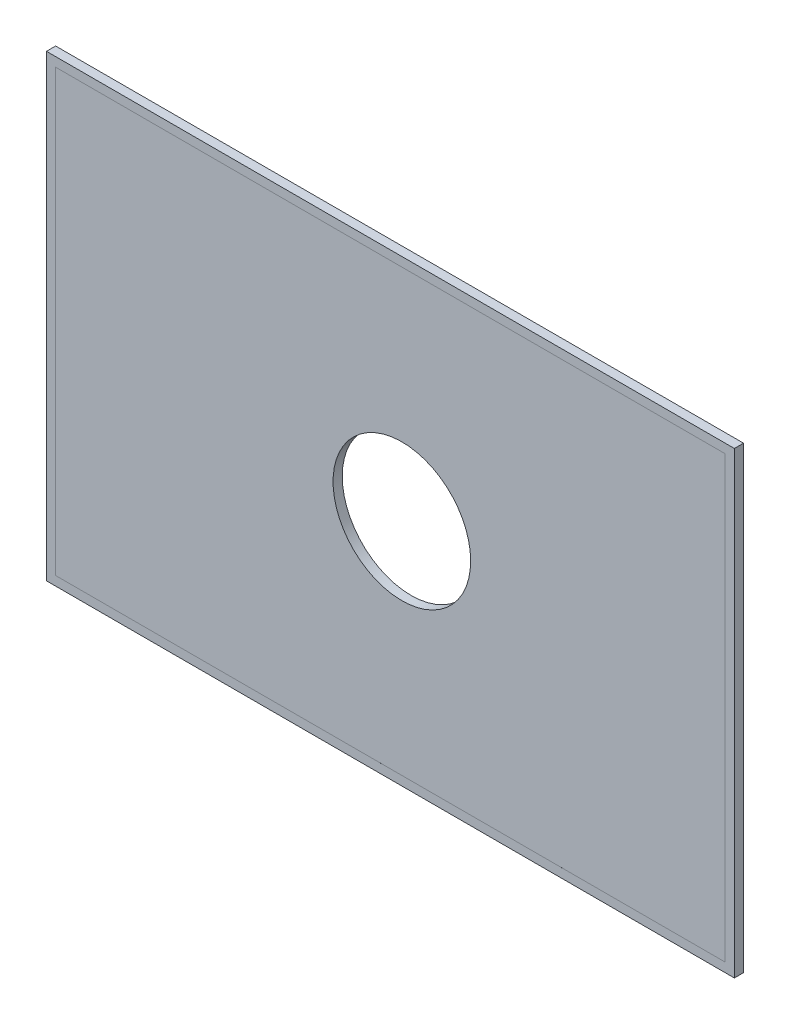
from build123d import *

# Parameters (mm, degrees)
ESQUISSE2_W             = 150
ESQUISSE2_H             = 100
BOSS_EXTRU_1_DEPTH      = 2
ESQUISSE3_W             = 146
ESQUISSE3_H             = 96
ENL_V_MAT_EXTRU_1_DEPTH = 0.0001
ESQUISSE4_R             = 15
ENL_V_MAT_EXTRU_2_DEPTH = 2.5


with BuildPart() as part:
    # Esquisse2 → Boss.-Extru.1 (new body)
    with BuildSketch(Plane.XY):
        with Locations((75, 50)):
            Rectangle(ESQUISSE2_W, ESQUISSE2_H)
    extrude(amount=BOSS_EXTRU_1_DEPTH)

    # Esquisse3 → Enlèv. mat.-Extru.1 (cut)
    with BuildSketch(Plane.XY.offset(2)):
        with Locations((75, 50)):
            Rectangle(ESQUISSE3_W, ESQUISSE3_H)
    extrude(amount=-ENL_V_MAT_EXTRU_1_DEPTH, mode=Mode.SUBTRACT)

    # Esquisse4 → Enlèv. mat.-Extru.2 (cut)
    with BuildSketch(Plane.XY.offset(1.9999)):
        with Locations((77.5, 50)):
            Circle(ESQUISSE4_R)
    extrude(amount=-ENL_V_MAT_EXTRU_2_DEPTH, mode=Mode.SUBTRACT)


solid = part.part
